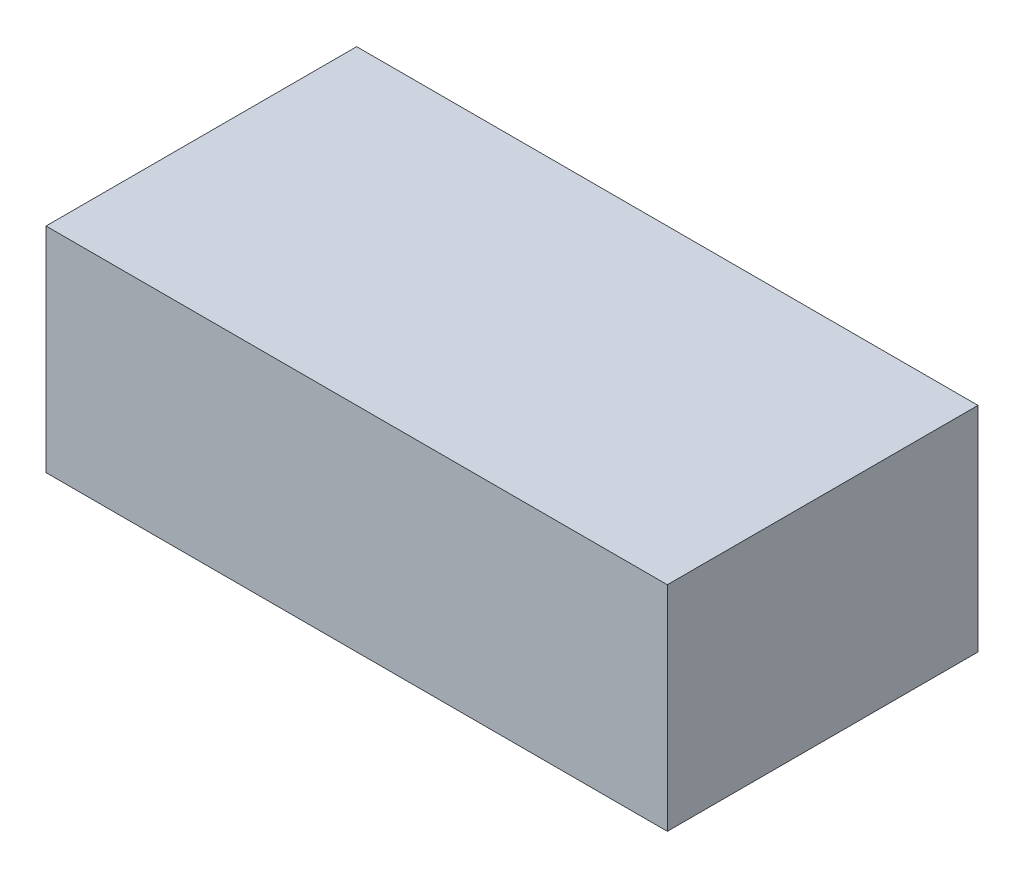
from build123d import *

# Parameters (mm, degrees)
SKETCH1_W           = 3.2
SKETCH1_H           = 1.6
BOSS_EXTRUDE1_DEPTH = 1.1


with BuildPart() as part:
    # Sketch1 → Boss-Extrude1 (new body)
    with BuildSketch(Plane(origin=(0, 0, 0), x_dir=(1, 0, 0), z_dir=(0, 1, 0))):
        Rectangle(SKETCH1_W, SKETCH1_H)
    extrude(amount=BOSS_EXTRUDE1_DEPTH)


solid = part.part
